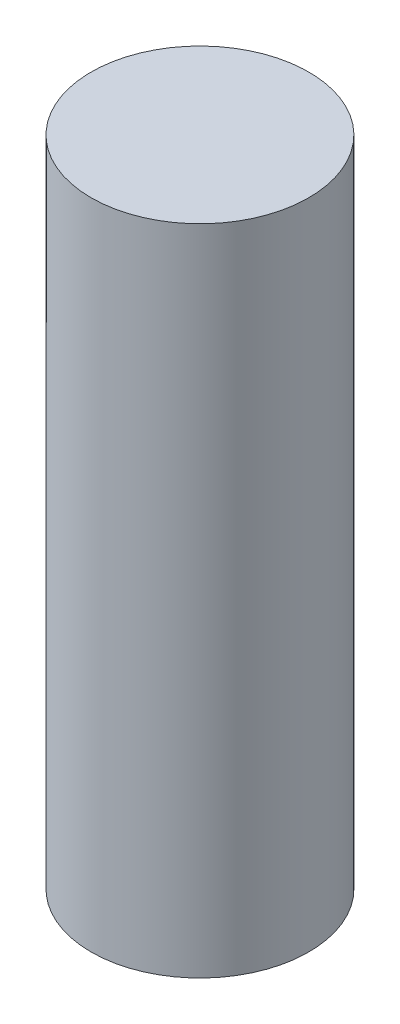
from build123d import *

# Parameters (mm, degrees)
SKETCH1_R           = 6
BOSS_EXTRUDE1_DEPTH = 36


with BuildPart() as part:
    # Sketch1 → Boss-Extrude1 (new body)
    with BuildSketch(Plane(origin=(0, 0, 0), x_dir=(1, 0, 0), z_dir=(0, 1, 0))):
        Circle(SKETCH1_R)
    extrude(amount=BOSS_EXTRUDE1_DEPTH)


solid = part.part
